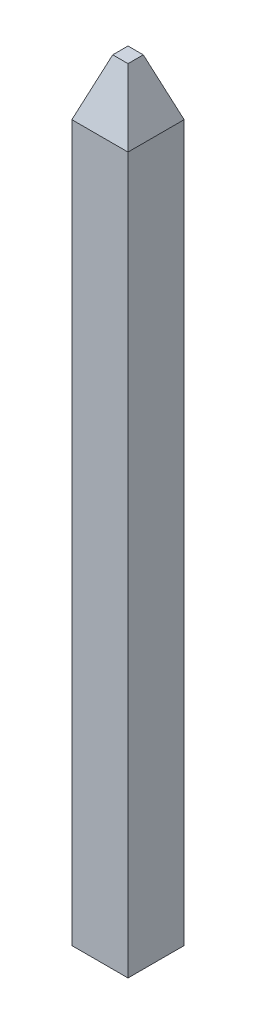
from build123d import *

# Parameters (mm, degrees)
SKETCH1_W           = 0.5
SKETCH1_H           = 0.5
SKETCH3_W           = 0.5
SKETCH3_H           = 0.5
BOSS_EXTRUDE1_DEPTH = 0.5
BOSS_EXTRUDE1_TAPER = 20


with BuildPart() as part:
    # Sweep1: sweep along a path in Sketch2
    with BuildLine(Plane.XY) as sweep1_path:
        Line((0, 0), (0, 6.37))
    # Sketch1 → Sweep1 (sweep)
    with BuildSketch(Plane(origin=(0, 0, 0), x_dir=(1, 0, 0), z_dir=(0, 1, 0))):
        Rectangle(SKETCH1_W, SKETCH1_H)
    sweep(path=sweep1_path.line)

    # Sketch3 → Boss-Extrude1 (add)
    with BuildSketch(Plane(origin=(0, 6.37, 0), x_dir=(1, 0, 0), z_dir=(0, 1, 0))):
        Rectangle(SKETCH3_W, SKETCH3_H)
    extrude(amount=BOSS_EXTRUDE1_DEPTH, taper=BOSS_EXTRUDE1_TAPER)


solid = part.part
